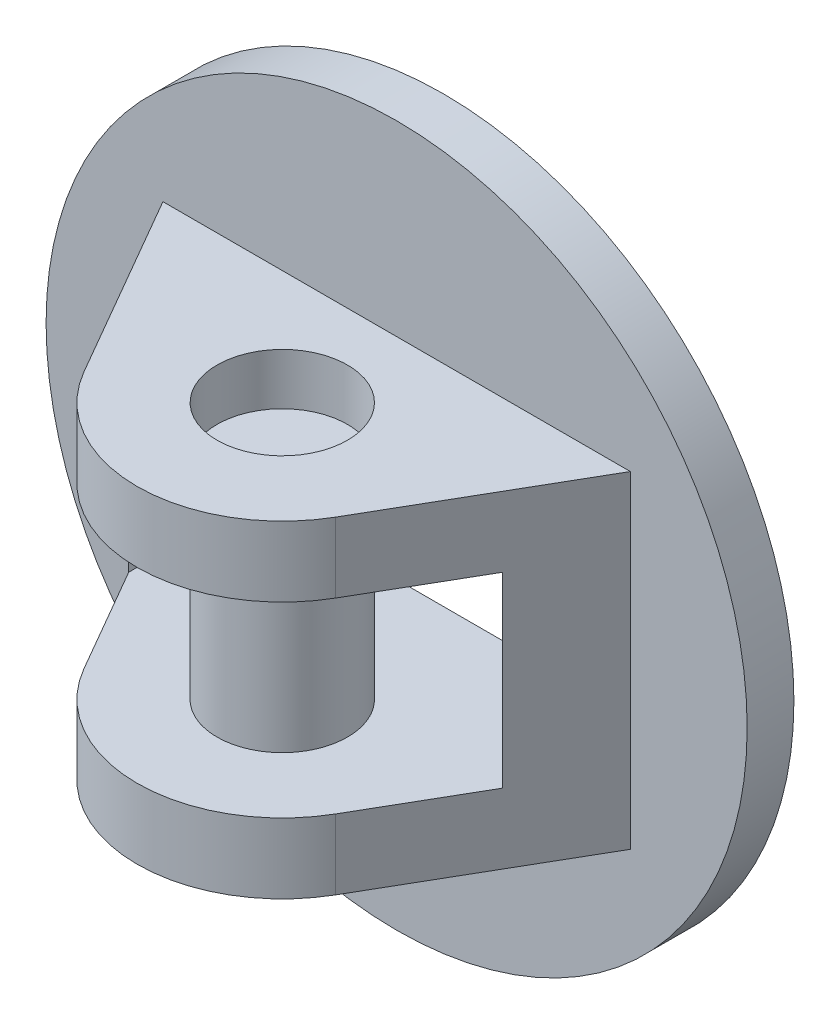
from build123d import *

# Parameters (mm, degrees)
SKETCH2_R               = 37.5
EXTRUDE1_DEPTH          = 5
SKETCH4_R               = 6.975515666
EXTRUDE2_DEPTH          = 17.5
SKETCH5_W               = 40
SKETCH5_H               = 20
CUT_EXTRUDE3_DEPTH      = 28.767090063
CUT_EXTRUDE3_DEPTH_BACK = 6
SKETCH6_R               = 6.975
EXTRUDE3_DEPTH          = 22
EXTRUDE3_DEPTH_BACK     = 2


with BuildPart() as part:
    # Sketch2 → Extrude1 (new body)
    with BuildSketch(Plane.XY):
        Circle(SKETCH2_R)
    extrude(amount=EXTRUDE1_DEPTH)

    # Sketch4 → Extrude2 (add, symmetric)
    with BuildSketch(Plane(origin=(0, 0, 0), x_dir=(-1, 0, 0), z_dir=(0, 1, 0))):
        with BuildLine():
            Line((-25, 5), (25, 5))
            Line((25, 5), (13.452994616, 25))
            ThreePointArc((13.452994616, 25), (0, 32.767090063), (-13.452994616, 25))
            Line((-13.452994616, 25), (-25, 5))
        make_face()
        with Locations((0, 17.232909937)):
            Circle(SKETCH4_R, mode=Mode.SUBTRACT)
    extrude(amount=EXTRUDE2_DEPTH, both=True)

    # Sketch5 → Cut-Extrude3 (cut, two sides)
    with BuildSketch(Plane.XY.offset(5)) as cut_extrude3_sk:
        Rectangle(SKETCH5_W, SKETCH5_H)
    extrude(amount=CUT_EXTRUDE3_DEPTH, mode=Mode.SUBTRACT)
    extrude(cut_extrude3_sk.sketch, amount=-CUT_EXTRUDE3_DEPTH_BACK, mode=Mode.SUBTRACT)


with BuildPart() as body_2:
    # Sketch6 → Extrude3 (new body, two sides)
    with BuildSketch(Plane(origin=(0, -10, 0), x_dir=(-1, 0, 0), z_dir=(0, 1, 0))) as extrude3_sk:
        with Locations((0, 17.232909937)):
            Circle(SKETCH6_R)
    extrude(amount=EXTRUDE3_DEPTH)
    extrude(extrude3_sk.sketch, amount=-EXTRUDE3_DEPTH_BACK)


solid = Compound([part.part, body_2.part])
